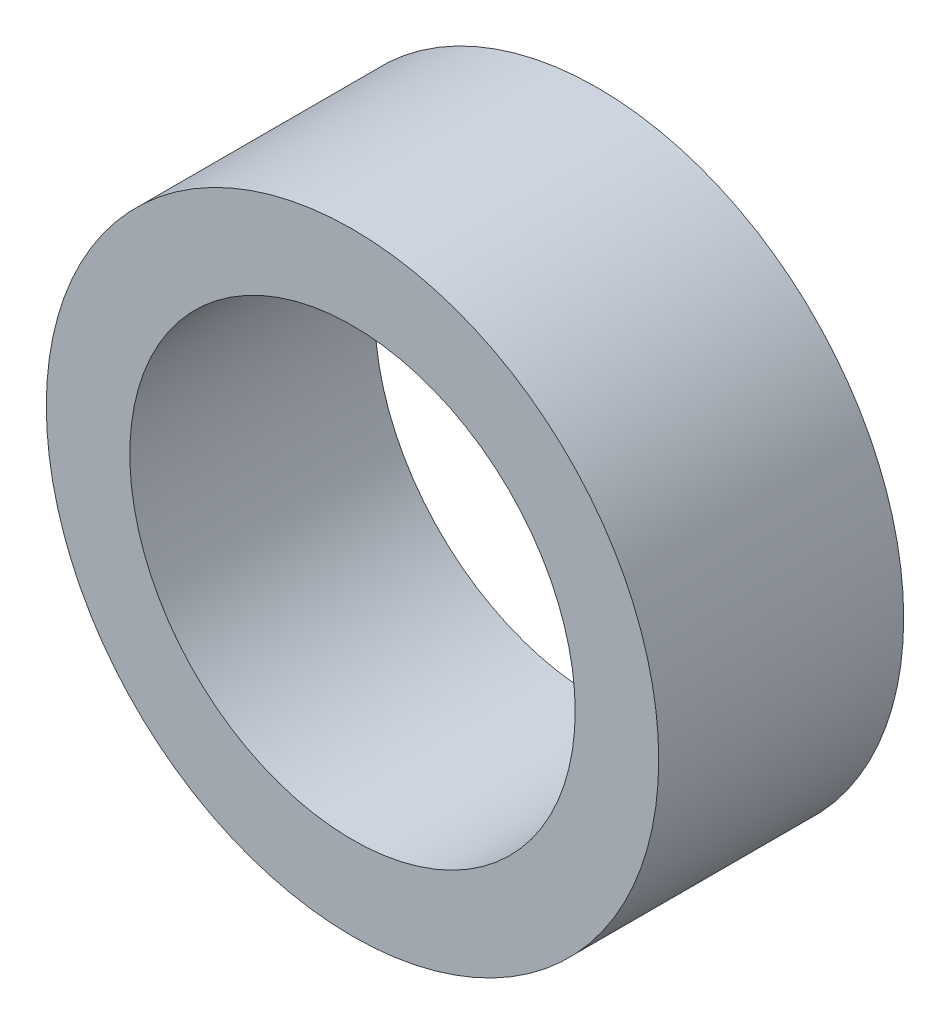
from build123d import *

# Parameters (mm, degrees)
SKETCH1_R           = 11
SKETCH1_R_2         = 8
BOSS_EXTRUDE1_DEPTH = 8.8


with BuildPart() as part:
    # Sketch1 → Boss-Extrude1 (new body)
    with BuildSketch(Plane.XY):
        Circle(SKETCH1_R)
        Circle(SKETCH1_R_2, mode=Mode.SUBTRACT)
    extrude(amount=BOSS_EXTRUDE1_DEPTH)


solid = part.part
